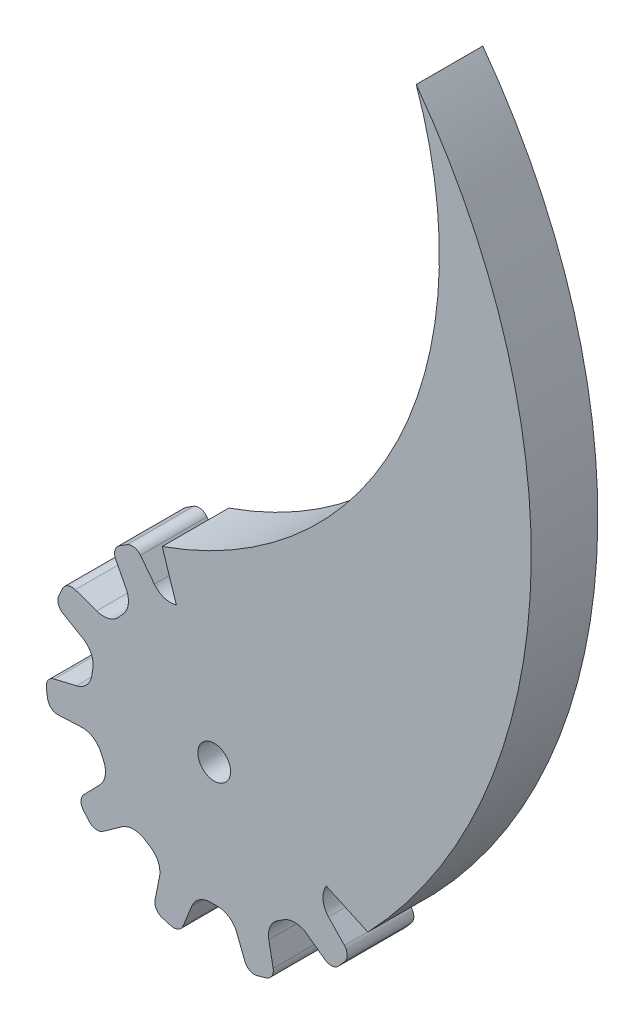
from build123d import *

# Parameters (mm, degrees)
ESBO_O1_R                = 1.6
RESSALTO_EXTRUS_O1_DEPTH = 6.5
RESSALTO_EXTRUS_O2_DEPTH = 6.5


with BuildPart() as part:
    # Esboço1 → Ressalto-extrusão1 (new body)
    with BuildSketch(Plane.XY):
        with BuildLine():
            Line((7.237292739, 13.882644275), (5.840999253, 12.115479156))
            ThreePointArc((5.840999253, 12.115479156), (4.855639954, 11.442537909), (3.66244261, 11.450473127))
            ThreePointArc((3.66244261, 11.450473127), (3.390740604, 11.533850132), (3.117143568, 11.610781054))
            ThreePointArc((3.117143568, 11.610781054), (2.102970634, 12.257593135), (1.64323621, 13.369149192))
            Line((1.64323621, 13.369149192), (1.451023847, 15.579942687))
            ThreePointArc((1.451023847, 15.579942687), (1.141313879, 16.220426504), (0.484122849, 16.4928962))
            ThreePointArc((0.484122849, 16.4928962), (0.017522037, 16.499990696), (-0.449092791, 16.493887221))
            ThreePointArc((-0.449092791, 16.493887221), (-1.103704511, 16.225768855), (-1.417126065, 15.591599404))
            Line((-1.417126065, 15.591599404), (-1.636361298, 13.350072253))
            ThreePointArc((-1.636361298, 13.350072253), (-2.101478783, 12.251232594), (-3.109550367, 11.612816937))
            ThreePointArc((-3.109550367, 11.612816937), (-3.383197652, 11.536064942), (-3.654954122, 11.452865627))
            ThreePointArc((-3.654954122, 11.452865627), (-4.857823698, 11.448695291), (-5.845529481, 12.135244556))
            Line((-5.845529481, 12.135244556), (-7.202474013, 13.891164545))
            ThreePointArc((-7.202474013, 13.891164545), (-7.809290312, 14.262531969), (-8.509462826, 14.136443768))
            ThreePointArc((-8.509462826, 14.136443768), (-8.905827982, 13.890148593), (-9.295069567, 13.632743002))
            ThreePointArc((-9.295069567, 13.632743002), (-9.700808257, 13.053277663), (-9.621617356, 12.350331887))
            Line((-9.621617356, 12.350331887), (-8.594188699, 10.346111737))
            ThreePointArc((-8.594188699, 10.346111737), (-8.391392855, 9.170247495), (-8.894283074, 8.088173422))
            ThreePointArc((-8.894283074, 8.088173422), (-9.082994557, 7.875660644), (-9.266629702, 7.658746286))
            ThreePointArc((-9.266629702, 7.658746286), (-10.276293328, 7.004917585), (-11.478380864, 7.048485517))
            Line((-11.478380864, 7.048485517), (-13.569237263, 7.792039811))
            ThreePointArc((-13.569237263, 7.792039811), (-14.280500006, 7.776384308), (-14.80135418, 7.291770323))
            ThreePointArc((-14.80135418, 7.291770323), (-15.001640543, 6.870282455), (-15.189927432, 6.443299203))
            ThreePointArc((-15.189927432, 6.443299203), (-15.217973923, 5.736463043), (-14.771313119, 5.187921259))
            Line((-14.771313119, 5.187921259), (-12.823421912, 4.057333846))
            ThreePointArc((-12.823421912, 4.057333846), (-12.017098986, 3.177773609), (-11.855143748, 1.995591994))
            ThreePointArc((-11.855143748, 1.995591994), (-11.899004868, 1.714789737), (-11.936215827, 1.433029113))
            ThreePointArc((-11.936215827, 1.433029113), (-12.432112436, 0.33712804), (-13.466927425, -0.276117871))
            Line((-13.466927425, -0.276117871), (-15.627863558, -0.781002507))
            ThreePointArc((-15.627863558, -0.781002507), (-16.21775185, -1.178710425), (-16.393920163, -1.867988679))
            ThreePointArc((-16.393920163, -1.867988679), (-16.334538228, -2.330849819), (-16.262090664, -2.791846566))
            ThreePointArc((-16.262090664, -2.791846566), (-15.903540395, -3.401638061), (-15.231221337, -3.621617713))
            Line((-15.231221337, -3.621617713), (-12.981309273, -3.519618873))
            ThreePointArc((-12.981309273, -3.519618873), (-11.827461098, -3.823620944), (-11.052080047, -4.730575792))
            ThreePointArc((-11.052080047, -4.730575792), (-10.937165208, -4.990514794), (-10.816137764, -5.247664678))
            ThreePointArc((-10.816137764, -5.247664678), (-10.640823687, -6.437697275), (-11.179819681, -7.513055786))
            Line((-11.179819681, -7.513055786), (-12.724753595, -9.106082048))
            ThreePointArc((-12.724753595, -9.106082048), (-13.005982071, -9.759572927), (-12.781532328, -10.434674473))
            ThreePointArc((-12.781532328, -10.434674473), (-12.48133544, -10.791953745), (-12.171155012, -11.140600777))
            ThreePointArc((-12.171155012, -11.140600777), (-11.53984516, -11.459743115), (-10.855324398, -11.28131865))
            Line((-10.855324398, -11.28131865), (-9.017722662, -9.979117468))
            ThreePointArc((-9.017722662, -9.979117468), (-7.88268788, -9.611042864), (-6.740059022, -9.954819189))
            ThreePointArc((-6.740059022, -9.954819189), (-6.502852873, -10.11136614), (-6.262012384, -10.262262012))
            ThreePointArc((-6.262012384, -10.262262012), (-5.471148601, -11.168599193), (-5.343198182, -12.364651574))
            Line((-5.343198182, -12.364651574), (-5.781624274, -14.540044879))
            ThreePointArc((-5.781624274, -14.540044879), (-5.664904879, -15.241839982), (-5.111098288, -15.68842485))
            ThreePointArc((-5.111098288, -15.68842485), (-4.665396838, -15.826688609), (-4.215963642, -15.952292956))
            ThreePointArc((-4.215963642, -15.952292956), (-3.512330623, -15.879460702), (-3.032938663, -15.359280625))
            Line((-3.032938663, -15.359280625), (-2.191072822, -13.270316777))
            ThreePointArc((-2.191072822, -13.270316777), (-1.435216957, -12.347026583), (-0.28811688, -12.018477831))
            ThreePointArc((-0.28811688, -12.018477831), (-0.003930697, -12.02193018), (0.280257682, -12.018663667))
            ThreePointArc((0.280257682, -12.018663667), (1.435577508, -12.35354978), (2.189850988, -13.290557851))
            Line((2.189850988, -13.290557851), (2.997129903, -15.357646195))
            ThreePointArc((2.997129903, -15.357646195), (3.474739585, -15.884930537), (4.182073344, -15.961211187))
            ThreePointArc((4.182073344, -15.961211187), (4.631772295, -15.836561666), (5.077766396, -15.699244836))
            ThreePointArc((5.077766396, -15.699244836), (5.630324069, -15.257561714), (5.752383667, -14.560779526))
            Line((5.752383667, -14.560779526), (5.331227158, -12.348284272))
            ThreePointArc((5.331227158, -12.348284272), (5.46792521, -11.162916602), (6.255300336, -10.26635468))
            ThreePointArc((6.255300336, -10.26635468), (6.496239447, -10.11561633), (6.733547915, -9.959224527))
            ThreePointArc((6.733547915, -9.959224527), (7.886517902, -9.616335598), (9.027637941, -9.996805918))
            Line((9.027637941, -9.996805918), (10.824316513, -11.299303357))
            ThreePointArc((10.824316513, -11.299303357), (11.511178782, -11.484667883), (12.147466239, -11.166425748))
            ThreePointArc((12.147466239, -11.166425748), (12.458386452, -10.81843829), (12.759341481, -10.461797406))
            ThreePointArc((12.759341481, -10.461797406), (12.985390652, -9.791494687), (12.711364828, -9.139333809))
            Line((12.711364828, -9.139333809), (11.160900184, -7.505758759))
            ThreePointArc((11.160900184, -7.505758759), (10.635039757, -6.434659473), (10.812703893, -5.254736456))
            ThreePointArc((10.812703893, -5.254736456), (10.933899467, -4.99766577), (11.048984261, -4.737801968))
            ThreePointArc((11.048984261, -4.737801968), (11.833544585, -3.826002809), (12.999213634, -3.529138739))
            Line((12.999213634, -3.529138739), (15.21485911, -3.65351154))
            ThreePointArc((15.21485911, -3.65351154), (15.89290005, -3.438104324), (16.256124433, -2.826379032))
            ThreePointArc((16.256124433, -2.826379032), (16.329550936, -2.365537195), (16.389915799, -1.902803219))
            ThreePointArc((16.389915799, -1.902803219), (16.217687452, -1.21669728), (15.63457747, -0.816214183))
            Line((15.63457747, -0.816214183), (13.44706626, -0.280207874))
            ThreePointArc((13.44706626, -0.280207874), (12.425604324, 0.336556574), (11.937150363, 1.425223464))
            ThreePointArc((11.937150363, 1.425223464), (11.900123661, 1.707008361), (11.856446173, 1.987839239))
            ThreePointArc((11.856446173, 1.987839239), (12.023504475, 3.179058838), (12.843630847, 4.059005053))
            Line((12.843630847, 4.059005053), (14.774791444, 5.152244377))
            ThreePointArc((14.774791444, 5.152244377), (15.228737846, 5.700033066), (15.203577979, 6.411023056))
            ThreePointArc((15.203577979, 6.411023056), (15.016198378, 6.838405244), (14.816807657, 7.260317546))
            ThreePointArc((14.816807657, 7.260317546), (14.300983076, 7.744392916), (13.593922234, 7.766047679))
            Line((13.593922234, 7.766047679), (11.463883812, 7.034307031))
            ThreePointArc((11.463883812, 7.034307031), (10.271127314, 7.000918286), (9.271635936, 7.652685004))
            ThreePointArc((9.271635936, 7.652685004), (9.088142675, 7.869719398), (8.899570199, 8.082355534))
            ThreePointArc((8.899570199, 8.082355534), (8.396086648, 9.174791766), (8.610286014, 10.358443421))
            Line((8.610286014, 10.358443421), (9.643831887, 12.322199108))
            ThreePointArc((9.643831887, 12.322199108), (9.729558977, 13.028450232), (9.324002941, 13.612970622))
            ThreePointArc((9.324002941, 13.612970622), (8.935308934, 13.871202336), (8.539467774, 14.118338788))
            ThreePointArc((8.539467774, 14.118338788), (7.843817619, 14.246693081), (7.237292739, 13.882644275))
        make_face()
        Circle(ESBO_O1_R, mode=Mode.SUBTRACT)
    extrude(amount=RESSALTO_EXTRUS_O1_DEPTH)

    # Esboço6 → Ressalto-extrusão2 (add)
    with BuildSketch(Plane.XY.offset(6.5)):
        with BuildLine():
            ThreePointArc((19.721119128, 67.164555089), (17.980474936, 36.295868824), (-5.07780376, 15.699232751))
            Line((-5.07780376, 15.699232751), (-3.385202507, 10.466155167))
            ThreePointArc((-3.385202507, 10.466155167), (6.471582976, 8.894864461), (11, 0))
            ThreePointArc((11, 0), (10.747375274, -2.343912268), (10.001104596, -4.580164501))
            Line((10.001104596, -4.580164501), (15.001656894, -6.870246751))
            ThreePointArc((15.001656894, -6.870246751), (30.834620096, 29.288282282), (19.721119128, 67.164555089))
        make_face()
    extrude(amount=-RESSALTO_EXTRUS_O2_DEPTH)


solid = part.part
